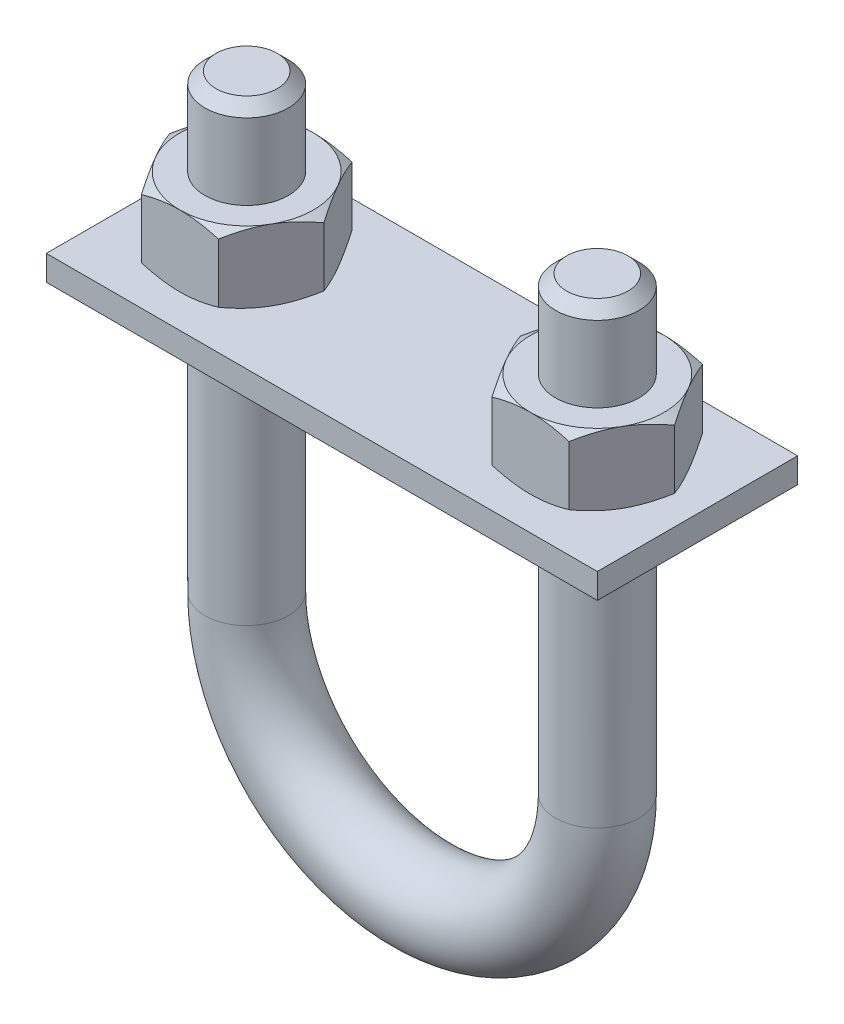
from build123d import *

# Parameters (mm, degrees)
SKETCH2_R           = 3.96875
BOSS_EXTRUDE1_DEPTH = 34.925
CHAMFER2_SIZE       = 1.058333333
SKETCH7_R           = 3.96875
SKETCH9_R           = 3.96875
BOSS_EXTRUDE2_DEPTH = 3.3734375
SKETCH10_OUTSIDE_W  = 257.161
SKETCH10_OUTSIDE_H  = 225.222
SKETCH10_OUTSIDE_R  = 6.35
CUT_EXTRUDE1_DEPTH  = 56.231770933
CUT_EXTRUDE1_TAPER  = 60
SKETCH11_OUTSIDE_W  = 117.847
SKETCH11_OUTSIDE_H  = 85.908
SKETCH11_OUTSIDE_R  = 6.35
CUT_EXTRUDE2_DEPTH  = 16.015104167
CUT_EXTRUDE2_TAPER  = 60
SKETCH12_W          = 52.3875
SKETCH12_H          = 19.05
BOSS_EXTRUDE3_DEPTH = 2.38125


with BuildPart() as part:
    # Sketch2 → Boss-Extrude1 (new body)
    with BuildSketch(Plane(origin=(0, 42.8625, 0), x_dir=(-1, 0, 0), z_dir=(0, 1, 0))):
        with Locations((16.66875, 0)):
            Circle(SKETCH2_R)
    extrude(amount=-BOSS_EXTRUDE1_DEPTH)

    # Chamfer2
    chamfer2_edges = [part.edges().sort_by_distance(p)[0] for p in [
        (-12.7, 42.8625, 0),
    ]]
    chamfer(chamfer2_edges, length=CHAMFER2_SIZE)


with BuildPart() as body_2:
    # Sweep1: sweep along a path in Sketch8
    with BuildLine(Plane.XY) as sweep1_path:
        Line((-16.66875, 7.9375), (-16.66875, 0))
        ThreePointArc((-16.66875, 0), (0, -16.66875), (16.66875, 0))
        Line((16.66875, 0), (16.66875, 7.9375))
    # Sketch7 → Sweep1 (sweep)
    with BuildSketch(Plane(origin=(0, 7.9375, 0), x_dir=(-1, 0, 0), z_dir=(0, 1, 0))):
        with Locations((16.66875, 0)):
            Circle(SKETCH7_R)
    sweep(path=sweep1_path.line)


with BuildPart() as body_3:
    # Body-Move_Copy1: copy of part
    add(part.part.moved(Location((33.3375, 0, 0))))


with BuildPart() as part_1:
    add(part.part)

    # Combine1: union body 2, body 3
    add(body_2.part)
    add(body_3.part)



with BuildPart() as body_2_2:
    # Sketch9 → Boss-Extrude2 (new body, symmetric)
    with BuildSketch(Plane(origin=(0, 31.220833333, 0), x_dir=(-1, 0, 0), z_dir=(0, 1, 0))):
        Polygon((-20.334924209, 6.35), (-24.001098419, 0), (-20.334924209, -6.35), (-13.002575791, -6.35), (-9.336401581, 0), (-13.002575791, 6.35), align=None)
        with Locations((-16.66875, 0)):
            Circle(SKETCH9_R, mode=Mode.SUBTRACT)
    extrude(amount=BOSS_EXTRUDE2_DEPTH, both=True)

    # Sketch10 outside → Cut-Extrude1 (cut, through all)
    with BuildSketch(Plane(origin=(0, 34.594270833, 0), x_dir=(1, 0, 0), z_dir=(0, 1, 0))):
        with Locations((1.6815, 0)):
            Rectangle(SKETCH10_OUTSIDE_W, SKETCH10_OUTSIDE_H)
        with Locations((16.66875, 0)):
            Circle(SKETCH10_OUTSIDE_R, mode=Mode.SUBTRACT)
    extrude(amount=-CUT_EXTRUDE1_DEPTH, taper=CUT_EXTRUDE1_TAPER, mode=Mode.SUBTRACT)

    # Sketch11 outside → Cut-Extrude2 (cut, through all)
    with BuildSketch(Plane.XZ.offset(-27.847395833)):
        with Locations((1.6815, 0)):
            Rectangle(SKETCH11_OUTSIDE_W, SKETCH11_OUTSIDE_H)
        with Locations((16.66875, 0)):
            Circle(SKETCH11_OUTSIDE_R, mode=Mode.SUBTRACT)
    extrude(amount=-CUT_EXTRUDE2_DEPTH, taper=CUT_EXTRUDE2_TAPER, mode=Mode.SUBTRACT)


with BuildPart() as body_3_2:
    # Body-Move_Copy2: copy of body 2 2
    add(body_2_2.part.moved(Location((-33.3375, 0, 0))))


with BuildPart() as part_2:
    add(part_1.part)

    add(body_2_2.part)  # Boss-Extrude3 merges body 2 2

    add(body_3_2.part)  # Boss-Extrude3 merges body 3 2
    # Sketch12 → Boss-Extrude3 (add)
    with BuildSketch(Plane(origin=(0, 27.847395833, 0), x_dir=(1, 0, 0), z_dir=(0, 1, 0))):
        Rectangle(SKETCH12_W, SKETCH12_H)
    extrude(amount=-BOSS_EXTRUDE3_DEPTH)


solid = part_2.part
